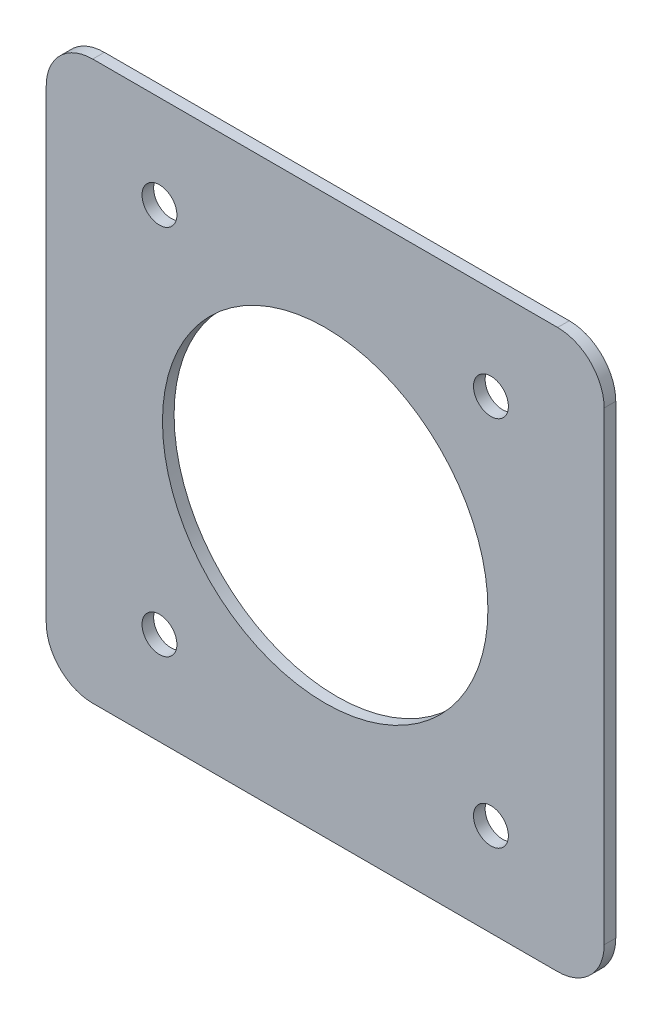
from build123d import *

# Parameters (mm, degrees)
SKETCH1_R           = 4.7625
BOSS_EXTRUDE1_DEPTH = 3.175
SKETCH2_R           = 44.45
CUT_EXTRUDE1_DEPTH  = 4.175


with BuildPart() as part:
    # Sketch1 → Boss-Extrude1 (new body)
    with BuildSketch(Plane.XY):
        with BuildLine():
            Line((-230.997719316, 150.485716341), (-103.997719316, 150.485716341))
            ThreePointArc((-103.997719316, 150.485716341), (-95.017463195, 146.765972462), (-91.297719316, 137.785716341))
            Line((-91.297719316, 137.785716341), (-91.297719316, 10.785716341))
            ThreePointArc((-91.297719316, 10.785716341), (-95.017463195, 1.80546022), (-103.997719316, -1.914283659))
            Line((-103.997719316, -1.914283659), (-230.997719316, -1.914283659))
            ThreePointArc((-230.997719316, -1.914283659), (-239.977975437, 1.80546022), (-243.697719316, 10.785716341))
            Line((-243.697719316, 10.785716341), (-243.697719316, 137.785716341))
            ThreePointArc((-243.697719316, 137.785716341), (-239.977975437, 146.765972462), (-230.997719316, 150.485716341))
        make_face()
        with Locations((-122.222219316, 125.085716341)):
            Circle(SKETCH1_R, mode=Mode.SUBTRACT)
        with Locations((-212.773219316, 125.085716341)):
            Circle(SKETCH1_R, mode=Mode.SUBTRACT)
        with Locations((-212.773219316, 23.485716341)):
            Circle(SKETCH1_R, mode=Mode.SUBTRACT)
        with Locations((-122.222219316, 23.485716341)):
            Circle(SKETCH1_R, mode=Mode.SUBTRACT)
    extrude(amount=BOSS_EXTRUDE1_DEPTH)

    # Sketch2 → Cut-Extrude1 (cut, through all)
    with BuildSketch(Plane.XY.offset(3.175)):
        with Locations((-167.497719316, 74.285716341)):
            Circle(SKETCH2_R)
    extrude(amount=-CUT_EXTRUDE1_DEPTH, mode=Mode.SUBTRACT)


solid = part.part
